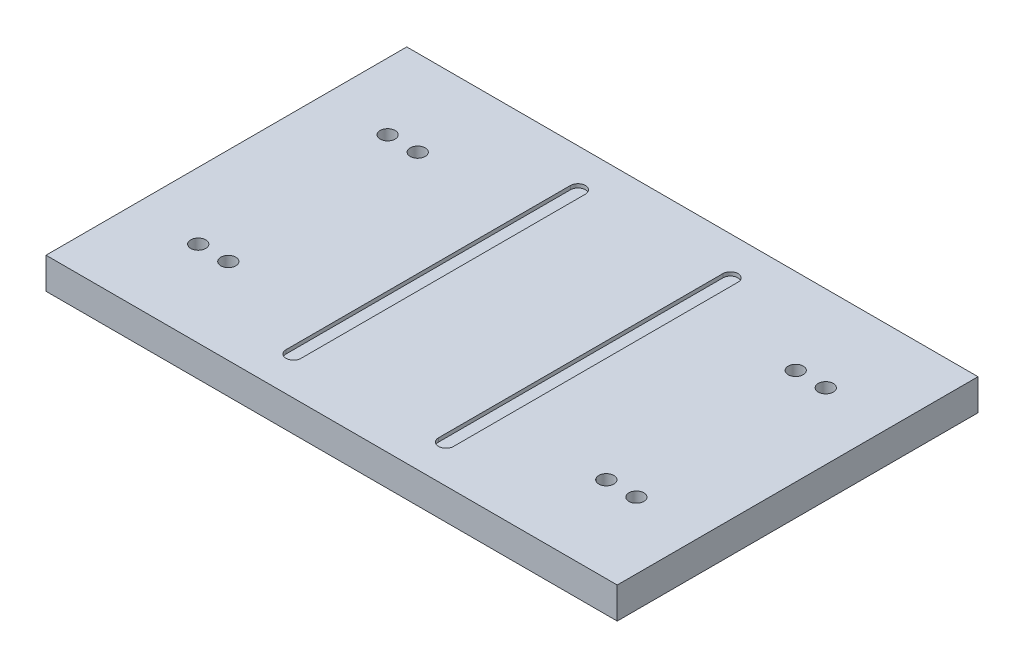
from build123d import *

# Parameters (mm, degrees)
SKETCH1_W           = 482.6
SKETCH1_H           = 304.8
BOSS_EXTRUDE1_DEPTH = 26.416
CUT_EXTRUDE3_DEPTH  = 3.175
SKETCH3_R           = 6.35
CUT_EXTRUDE2_DEPTH  = 27.416


with BuildPart() as part:
    # Sketch1 → Boss-Extrude1 (new body)
    with BuildSketch(Plane(origin=(0, 0, 0), x_dir=(1, 0, 0), z_dir=(0, 1, 0))):
        Rectangle(SKETCH1_W, SKETCH1_H)
    extrude(amount=BOSS_EXTRUDE1_DEPTH)

    # Sketch2 → Cut-Extrude3 (cut)
    with BuildSketch(Plane(origin=(0, 26.416, 0), x_dir=(1, 0, 0), z_dir=(0, 1, 0))):
        with BuildLine():
            Line((-70.7865, 120.142), (-70.7865, -120.142))
            ThreePointArc((-70.7865, -120.142), (-64.4365, -113.792), (-58.0865, -120.142))
            Line((-58.0865, -120.142), (-58.0865, 120.142))
            ThreePointArc((-58.0865, 120.142), (-64.4365, 113.792), (-70.7865, 120.142))
        make_face()
        with BuildLine():
            ThreePointArc((-58.0865, 120.142), (-64.4365, 126.492), (-70.7865, 120.142))
            Line((-70.7865, 120.142), (-58.0865, 120.142))
        make_face()
        with BuildLine():
            Line((-58.0865, 120.142), (-70.7865, 120.142))
            ThreePointArc((-70.7865, 120.142), (-64.4365, 113.792), (-58.0865, 120.142))
        make_face()
        with BuildLine():
            ThreePointArc((-58.0865, -120.142), (-64.4365, -113.792), (-70.7865, -120.142))
            Line((-70.7865, -120.142), (-58.0865, -120.142))
        make_face()
        with BuildLine():
            Line((-58.0865, -120.142), (-70.7865, -120.142))
            ThreePointArc((-70.7865, -120.142), (-64.4365, -126.492), (-58.0865, -120.142))
        make_face()
        with BuildLine():
            ThreePointArc((58.0865, 120.142), (64.4365, 113.792), (70.7865, 120.142))
            Line((70.7865, 120.142), (58.0865, 120.142))
        make_face()
        with BuildLine():
            Line((58.0865, 120.142), (70.7865, 120.142))
            ThreePointArc((70.7865, 120.142), (64.4365, 126.492), (58.0865, 120.142))
        make_face()
        with BuildLine():
            Line((70.7865, -120.142), (70.7865, 120.142))
            ThreePointArc((70.7865, 120.142), (64.4365, 113.792), (58.0865, 120.142))
            Line((58.0865, 120.142), (58.0865, -120.142))
            ThreePointArc((58.0865, -120.142), (64.4365, -113.792), (70.7865, -120.142))
        make_face()
        with BuildLine():
            ThreePointArc((58.0865, -120.142), (64.4365, -126.492), (70.7865, -120.142))
            Line((70.7865, -120.142), (58.0865, -120.142))
        make_face()
        with BuildLine():
            Line((58.0865, -120.142), (70.7865, -120.142))
            ThreePointArc((70.7865, -120.142), (64.4365, -113.792), (58.0865, -120.142))
        make_face()
    extrude(amount=-CUT_EXTRUDE3_DEPTH, mode=Mode.SUBTRACT)

    # Sketch3 → Cut-Extrude2 (cut, through all)
    with BuildSketch(Plane(origin=(0, 26.416, 0), x_dir=(1, 0, 0), z_dir=(0, 1, 0))):
        with Locations((-185.0865, -80.01)):
            Circle(SKETCH3_R)
        with Locations((-159.6865, -80.01)):
            Circle(SKETCH3_R)
        with Locations((-159.6865, 80.01)):
            Circle(SKETCH3_R)
        with Locations((-185.0865, 80.01)):
            Circle(SKETCH3_R)
        with Locations((159.6865, -80.01)):
            Circle(SKETCH3_R)
        with Locations((185.0865, -80.01)):
            Circle(SKETCH3_R)
        with Locations((159.6865, 80.01)):
            Circle(SKETCH3_R)
        with Locations((185.0865, 80.01)):
            Circle(SKETCH3_R)
    extrude(amount=-CUT_EXTRUDE2_DEPTH, mode=Mode.SUBTRACT)


solid = part.part
